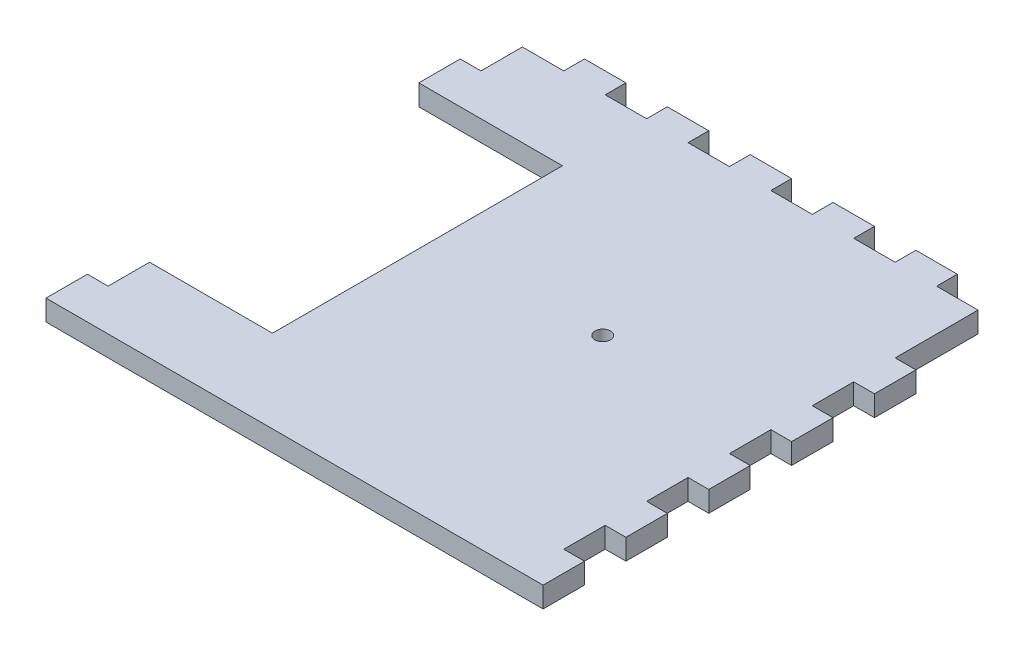
from build123d import *

# Parameters (mm, degrees)
SKETCH1_W               = 279.4
SKETCH1_H               = 279.4
BOSS_EXTRUDE1_DEPTH     = 12.7
SKETCH2_W               = 25.4
SKETCH2_H               = 12.7
BOSS_EXTRUDE2_DEPTH     = 12.7
LPATTERN1_COUNT         = 5
LPATTERN1_PITCH         = 50.8
MIRROR1_COPY_1_SKETCH_W = 25.4
MIRROR1_COPY_1_SKETCH_H = 12.7
MIRROR1_COPY_1_DEPTH    = 12.7
MIRROR1_COPY_2_SKETCH_W = 25.4
MIRROR1_COPY_2_SKETCH_H = 12.7
MIRROR1_COPY_2_DEPTH    = 12.7
MIRROR1_COPY_3_SKETCH_W = 25.4
MIRROR1_COPY_3_SKETCH_H = 12.7
MIRROR1_COPY_3_DEPTH    = 12.7
MIRROR1_COPY_4_SKETCH_W = 25.4
MIRROR1_COPY_4_SKETCH_H = 12.7
MIRROR1_COPY_4_DEPTH    = 12.7
SKETCH3_W               = 25.4
SKETCH3_H               = 12.7
BOSS_EXTRUDE3_DEPTH     = 12.7
LPATTERN2_COUNT         = 5
LPATTERN2_PITCH         = 50.8
SKETCH6_R               = 4.7625
CUT_EXTRUDE1_DEPTH      = 13.7
SKETCH8_W               = 88.066093183
SKETCH8_H               = 177.8
CUT_EXTRUDE3_DEPTH      = 13.7
SKETCH9_W               = 25.4
SKETCH9_H               = 12.7
BOSS_EXTRUDE4_DEPTH     = 12.7


with BuildPart() as part:
    # Sketch1 → Boss-Extrude1 (new body)
    with BuildSketch(Plane(origin=(0, 0, 0), x_dir=(1, 0, 0), z_dir=(0, 1, 0))):
        Rectangle(SKETCH1_W, SKETCH1_H)
    extrude(amount=BOSS_EXTRUDE1_DEPTH)

    # Sketch2 → Boss-Extrude2 (add)
    with BuildSketch(Plane(origin=(139.7, 0, 0), x_dir=(0, 0, -1), z_dir=(1, 0, 0))):
        with Locations((-127, 6.35)):
            Rectangle(SKETCH2_W, SKETCH2_H)
    boss_extrude2 = extrude(amount=BOSS_EXTRUDE2_DEPTH)

    # LPattern1: Boss-Extrude2 ×5
    with Locations(*[(0, 0, -i * LPATTERN1_PITCH) for i in range(1, LPATTERN1_COUNT)]):
        add(boss_extrude2)

    # Mirror1: Boss-Extrude2 across plane
    add(boss_extrude2.mirror(Plane(origin=(0, 0, 0), x_dir=(0, 0, 1), z_dir=(1, 0, 0))))

    # Mirror1 copy 1 sketch → Mirror1 copy 1 (add)
    with BuildSketch(Plane(origin=(-139.7, 0, -50.8), x_dir=(0, 0, -1), z_dir=(-1, 0, 0))):
        with Locations((-127, -6.35)):
            Rectangle(MIRROR1_COPY_1_SKETCH_W, MIRROR1_COPY_1_SKETCH_H)
    extrude(amount=MIRROR1_COPY_1_DEPTH)

    # Mirror1 copy 2 sketch → Mirror1 copy 2 (add)
    with BuildSketch(Plane(origin=(-139.7, 0, -101.6), x_dir=(0, 0, -1), z_dir=(-1, 0, 0))):
        with Locations((-127, -6.35)):
            Rectangle(MIRROR1_COPY_2_SKETCH_W, MIRROR1_COPY_2_SKETCH_H)
    extrude(amount=MIRROR1_COPY_2_DEPTH)

    # Mirror1 copy 3 sketch → Mirror1 copy 3 (add)
    with BuildSketch(Plane(origin=(-139.7, 0, -152.4), x_dir=(0, 0, -1), z_dir=(-1, 0, 0))):
        with Locations((-127, -6.35)):
            Rectangle(MIRROR1_COPY_3_SKETCH_W, MIRROR1_COPY_3_SKETCH_H)
    extrude(amount=MIRROR1_COPY_3_DEPTH)

    # Mirror1 copy 4 sketch → Mirror1 copy 4 (add)
    with BuildSketch(Plane(origin=(-139.7, 0, -203.2), x_dir=(0, 0, -1), z_dir=(-1, 0, 0))):
        with Locations((-127, -6.35)):
            Rectangle(MIRROR1_COPY_4_SKETCH_W, MIRROR1_COPY_4_SKETCH_H)
    extrude(amount=MIRROR1_COPY_4_DEPTH)

    # Sketch3 → Boss-Extrude3 (add)
    with BuildSketch(Plane(origin=(0, 0, -139.7), x_dir=(-1, 0, 0), z_dir=(0, 0, -1))):
        with Locations((-101.6, 6.35)):
            Rectangle(SKETCH3_W, SKETCH3_H)
    boss_extrude3 = extrude(amount=BOSS_EXTRUDE3_DEPTH)

    # LPattern2: Boss-Extrude3 ×5
    with Locations(*[(-i * LPATTERN2_PITCH, 0, 0) for i in range(1, LPATTERN2_COUNT)]):
        add(boss_extrude3)

    # Sketch6 → Cut-Extrude1 (cut, through all)
    with BuildSketch(Plane(origin=(0, 12.7, 0), x_dir=(1, 0, 0), z_dir=(0, 1, 0))):
        with Locations((38.1, 11.176)):
            Circle(SKETCH6_R)
    extrude(amount=-CUT_EXTRUDE1_DEPTH, mode=Mode.SUBTRACT)

    # Sketch8 → Cut-Extrude3 (cut, through all)
    with BuildSketch(Plane(origin=(0, 12.7, 0), x_dir=(1, 0, 0), z_dir=(0, 1, 0))):
        with Locations((-108.366953408, 0)):
            Rectangle(SKETCH8_W, SKETCH8_H)
    extrude(amount=-CUT_EXTRUDE3_DEPTH, mode=Mode.SUBTRACT)

    # Sketch9 → Boss-Extrude4 (add)
    with BuildSketch(Plane.ZY.offset(139.7)):
        with Locations((-101.6, 6.35)):
            Rectangle(SKETCH9_W, SKETCH9_H)
    extrude(amount=BOSS_EXTRUDE4_DEPTH)


solid = part.part
